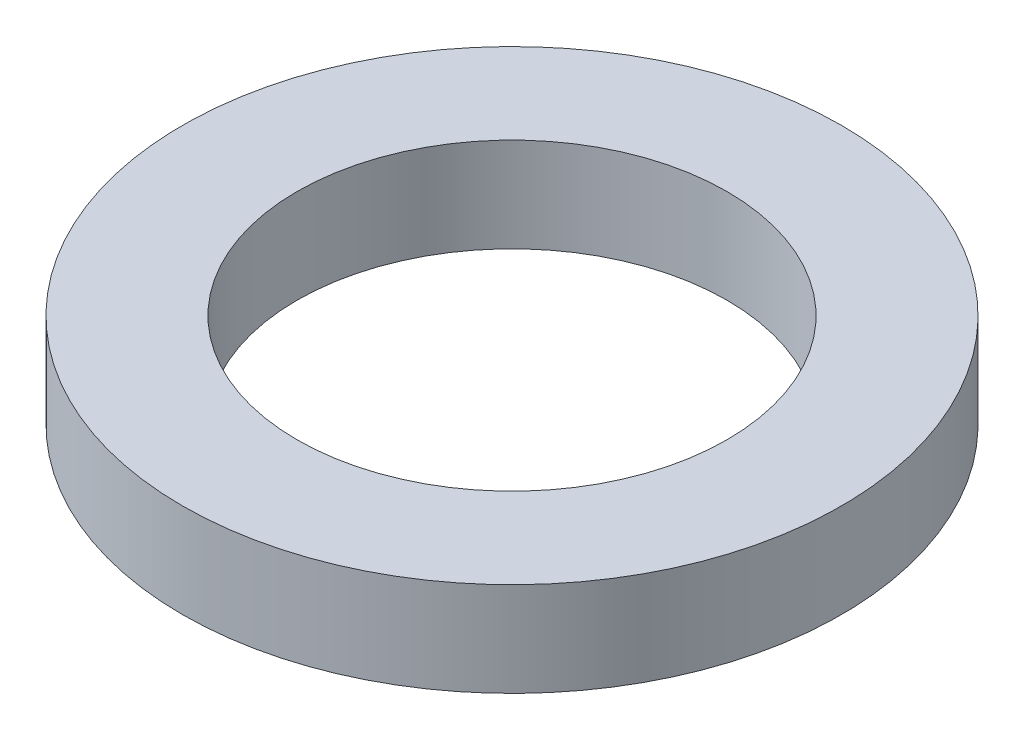
from build123d import *

# Parameters (mm, degrees)
SKETCH1_R           = 22.225
SKETCH1_R_2         = 14.5
BOSS_EXTRUDE1_DEPTH = 6.35


with BuildPart() as part:
    # Sketch1 → Boss-Extrude1 (new body)
    with BuildSketch(Plane(origin=(0, 0, 0), x_dir=(1, 0, 0), z_dir=(0, 1, 0))):
        Circle(SKETCH1_R)
        Circle(SKETCH1_R_2, mode=Mode.SUBTRACT)
    extrude(amount=BOSS_EXTRUDE1_DEPTH)


solid = part.part
